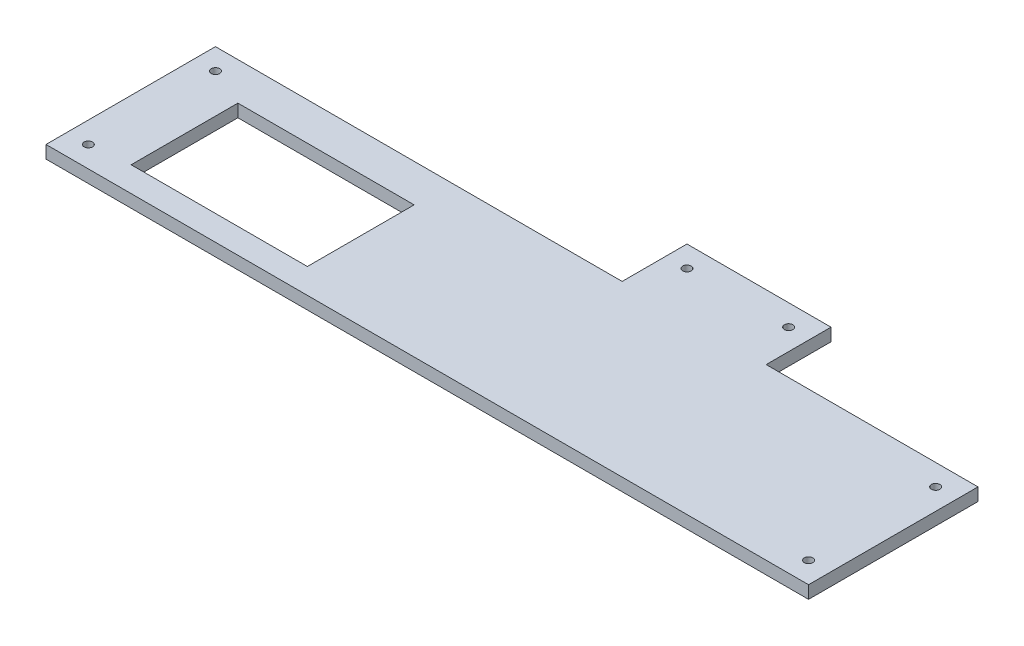
from build123d import *

# Parameters (mm, degrees)
SKETCH1_W              = 900
SKETCH1_H              = 200
SKETCH1_R              = 5
BOSS_EXTRUDE1_DEPTH    = 15
SKETCH2_W              = 208
SKETCH2_H              = 126
SHREDDER_OPENING_DEPTH = 16
SKETCH3_W              = 170
SKETCH3_H              = 76.5
SKETCH3_R              = 5
LEGS_ADD_ON_DEPTH      = 15


with BuildPart() as part:
    # Sketch1 → Boss-Extrude1 (new body)
    with BuildSketch(Plane(origin=(0, 0, 0), x_dir=(1, 0, 0), z_dir=(0, 1, 0))):
        Rectangle(SKETCH1_W, SKETCH1_H)
        with Locations((425, -75)):
            Circle(SKETCH1_R, mode=Mode.SUBTRACT)
        with Locations((425, 75)):
            Circle(SKETCH1_R, mode=Mode.SUBTRACT)
        with Locations((-425, -75)):
            Circle(SKETCH1_R, mode=Mode.SUBTRACT)
        with Locations((-425, 75)):
            Circle(SKETCH1_R, mode=Mode.SUBTRACT)
    extrude(amount=-BOSS_EXTRUDE1_DEPTH)

    # Sketch2 → Shredder Opening (cut, through all)
    with BuildSketch(Plane.XZ.offset(15)):
        with Locations((-275, 7.5)):
            Rectangle(SKETCH2_W, SKETCH2_H)
    extrude(amount=-SHREDDER_OPENING_DEPTH, mode=Mode.SUBTRACT)

    # Sketch3 → Legs add on (add, through all)
    with BuildSketch(Plane(origin=(0, 0, 0), x_dir=(1, 0, 0), z_dir=(0, 1, 0))):
        with Locations((115, 138.25)):
            Rectangle(SKETCH3_W, SKETCH3_H)
        with Locations((175, 151.5)):
            Circle(SKETCH3_R, mode=Mode.SUBTRACT)
        with Locations((55, 151.5)):
            Circle(SKETCH3_R, mode=Mode.SUBTRACT)
    extrude(amount=-LEGS_ADD_ON_DEPTH)


solid = part.part
